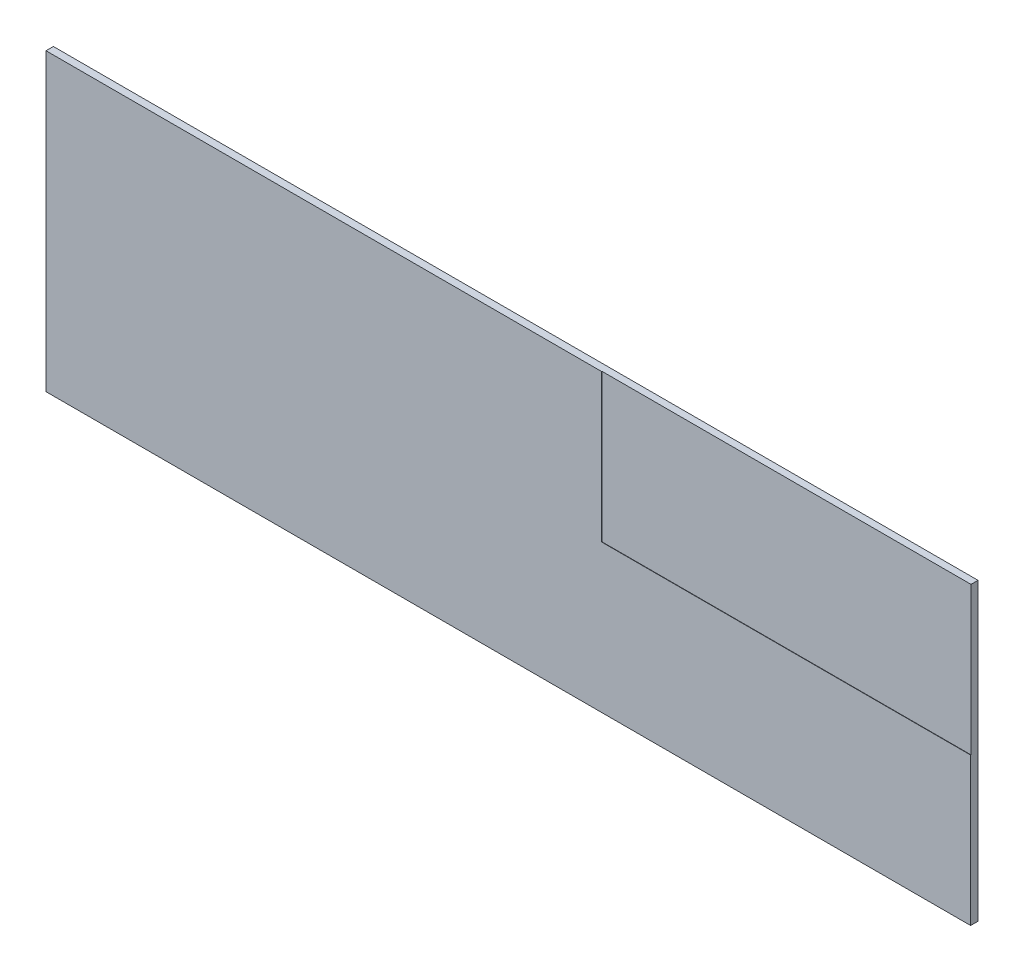
from build123d import *

# Parameters (mm, degrees)
CROQUIS1_W              = 25050
CROQUIS1_H              = 8000
SALIENTE_EXTRUIR1_DEPTH = 200
CROQUIS2_W              = 10000
CROQUIS2_H              = 4000
CORTAR_EXTRUIR1_DEPTH   = 10


with BuildPart() as part:
    # Croquis1 → Saliente-Extruir1 (new body)
    with BuildSketch(Plane.XY):
        Rectangle(CROQUIS1_W, CROQUIS1_H)
    extrude(amount=SALIENTE_EXTRUIR1_DEPTH)

    # Croquis2 → Cortar-Extruir1 (cut)
    with BuildSketch(Plane.XY.offset(200)):
        with Locations((7525, 2000)):
            Rectangle(CROQUIS2_W, CROQUIS2_H)
    extrude(amount=-CORTAR_EXTRUIR1_DEPTH, mode=Mode.SUBTRACT)


solid = part.part
